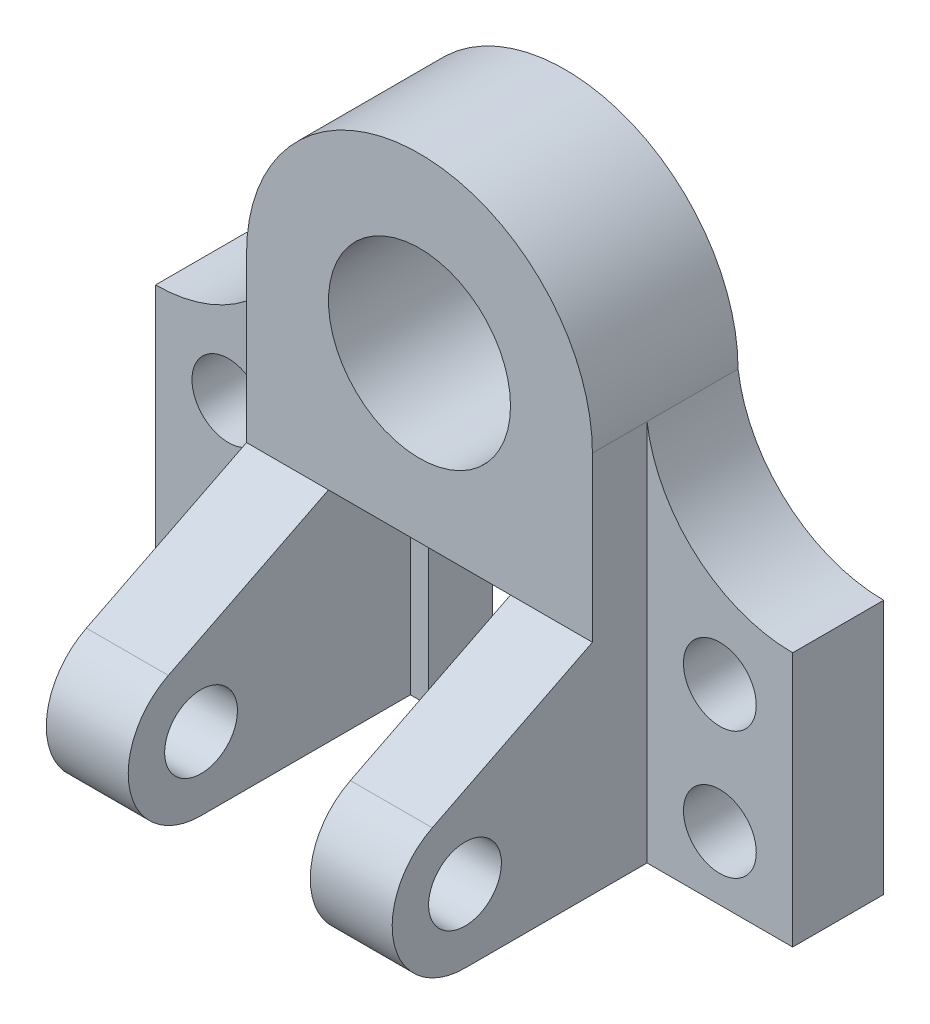
from build123d import *

# Parameters (mm, degrees)
SKETCH1_R              = 20
BOSS_EXTRUDE1_DEPTH    = 32
BOSS_EXTRUDE3_DEPTH    = 20
SKETCH16_W             = 32
SKETCH16_H             = 56
BOSS_EXTRUDE4_DEPTH    = 20
F_16_0MM_DOWEL_HOLE3_D = 16
LPATTERN5_COUNT        = 2
LPATTERN5_PITCH        = 28
MIRROR5_COPY_1_D       = 16
SKETCH25_R             = 8
BOSS_EXTRUDE6_DEPTH    = 18
SKETCH26_W             = 14
SKETCH26_H             = 48
BOSS_EXTRUDE7_DEPTH    = 4


with BuildPart() as part:
    # Sketch1 → Boss-Extrude1 (new body)
    with BuildSketch(Plane.XY):
        with BuildLine():
            Line((-38, 0), (-38, -36))
            Line((-38, -36), (38, -36))
            Line((38, -36), (38, 0))
            ThreePointArc((38, 0), (0, 38), (-38, 0))
        make_face()
        Circle(SKETCH1_R, mode=Mode.SUBTRACT)
    extrude(amount=BOSS_EXTRUDE1_DEPTH)

    # Sketch15 → Boss-Extrude3 (add)
    with BuildSketch(Plane.XY):
        with BuildLine():
            Line((-70, -28), (-38, -28))
            Line((-38, -28), (-38, 0))
            ThreePointArc((-38, 0), (-48.739708375, -20.011761858), (-70, -28))
        make_face()
    boss_extrude3 = extrude(amount=BOSS_EXTRUDE3_DEPTH)

    # Sketch16 → Boss-Extrude4 (add)
    with BuildSketch(Plane.XY):
        with Locations((-54, -56)):
            Rectangle(SKETCH16_W, SKETCH16_H)
    boss_extrude4 = extrude(amount=BOSS_EXTRUDE4_DEPTH)

    # Ø16.0mm Dowel Hole3 (through all)
    with Locations(Plane.XY.offset(20)):
        with Locations((-54, -42)):
            f_16_0mm_dowel_hole3 = Hole(F_16_0MM_DOWEL_HOLE3_D / 2)

    # LPattern5: Ø16.0mm Dowel Hole3 ×2
    with Locations(*[(0, -i * LPATTERN5_PITCH, 0) for i in range(1, LPATTERN5_COUNT)]):
        add(f_16_0mm_dowel_hole3, mode=Mode.SUBTRACT)

    # Mirror5: Boss-Extrude4, Boss-Extrude3, Ø16.0mm Dowel Hole3 across plane
    add(boss_extrude4.mirror(Plane(origin=(0, 0, 0), x_dir=(0, 0, 1), z_dir=(1, 0, 0))))
    add(boss_extrude3.mirror(Plane(origin=(0, 0, 0), x_dir=(0, 0, 1), z_dir=(1, 0, 0))))
    add(f_16_0mm_dowel_hole3.mirror(Plane(origin=(0, 0, 0), x_dir=(0, 0, 1), z_dir=(1, 0, 0))), mode=Mode.SUBTRACT)

    # Mirror5 copy 1 (through all)
    with Locations(Plane(origin=(0, -28, 20), x_dir=(-1, 0, 0), z_dir=(0, 0, 1))):
        with Locations((-54, 42)):
            Hole(MIRROR5_COPY_1_D / 2)

    # Sketch25 → Boss-Extrude6 (add)
    with BuildSketch(Plane(origin=(-38, 0, 0), x_dir=(0, 0, -1), z_dir=(1, 0, 0))):
        with BuildLine():
            Line((0, -84), (-60, -84))
            ThreePointArc((-60, -84), (-75.567317873, -71.695756248), (-67.191626537, -53.707326781))
            Line((-67.191626537, -53.707326781), (-32, -36))
            Line((-32, -36), (0, -36))
            Line((0, -36), (0, -84))
        make_face()
        with Locations(Location((-60, -68, 0), (0, 0, 90))):  # turned: the seam where the file's is
            Circle(SKETCH25_R, mode=Mode.SUBTRACT)
    boss_extrude6 = extrude(amount=BOSS_EXTRUDE6_DEPTH)

    # Sketch26 → Boss-Extrude7 (add)
    with BuildSketch(Plane(origin=(-20, 0, 0), x_dir=(0, 0, -1), z_dir=(1, 0, 0))):
        with Locations((-7, -60)):
            Rectangle(SKETCH26_W, SKETCH26_H)
    boss_extrude7 = extrude(amount=BOSS_EXTRUDE7_DEPTH)

    # Mirror6: Boss-Extrude6, Boss-Extrude7 across plane
    add(boss_extrude6.mirror(Plane(origin=(0, 0, 0), x_dir=(0, 0, 1), z_dir=(1, 0, 0))))
    add(boss_extrude7.mirror(Plane(origin=(0, 0, 0), x_dir=(0, 0, 1), z_dir=(1, 0, 0))))


solid = part.part
